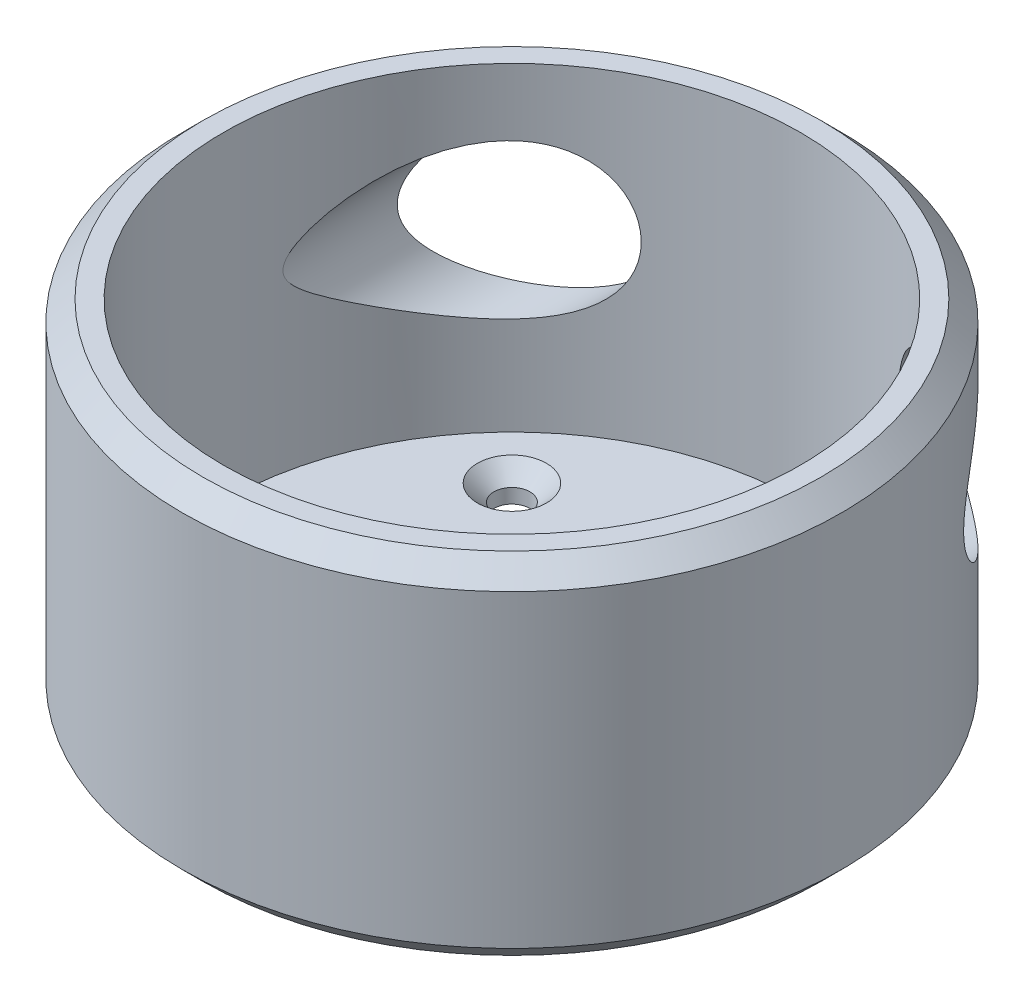
from build123d import *

# Parameters (mm, degrees)
SKETCH2_R           = 32
SKETCH2_R_2         = 28
BOSS_EXTRUDE1_DEPTH = 34
SKETCH3_R           = 28
BOSS_EXTRUDE2_DEPTH = 3
SKETCH4_R           = 12.5
CUT_EXTRUDE1_DEPTH  = 3
SKETCH5_R           = 2.6
SKETCH5_R_2         = 1.75
CUT_EXTRUDE2_DEPTH  = 4
CHAMFER1_SIZE       = 1.6
CHAMFER2_SIZE       = 2
CHAMFER3_SIZE       = 2
SKETCH7_R           = 7.5
CUT_EXTRUDE4_DEPTH  = 33


with BuildPart() as part:
    # Sketch2 → Boss-Extrude1 (new body)
    with BuildSketch(Plane(origin=(0, 0, 0), x_dir=(1, 0, 0), z_dir=(0, 1, 0))):
        Circle(SKETCH2_R)
        Circle(SKETCH2_R_2, mode=Mode.SUBTRACT)
    extrude(amount=BOSS_EXTRUDE1_DEPTH)

    # Sketch3 → Boss-Extrude2 (add)
    with BuildSketch(Plane.XZ):
        Circle(SKETCH3_R)
    extrude(amount=-BOSS_EXTRUDE2_DEPTH)

    # Sketch4 → Cut-Extrude1 (cut)
    with BuildSketch(Plane(origin=(0, 3, 0), x_dir=(1, 0, 0), z_dir=(0, 1, 0))):
        Circle(SKETCH4_R)
    extrude(amount=-CUT_EXTRUDE1_DEPTH, mode=Mode.SUBTRACT)

    # Sketch5 → Cut-Extrude2 (cut, through all)
    with BuildSketch(Plane(origin=(0, 3, 0), x_dir=(1, 0, 0), z_dir=(0, 1, 0))):
        Circle(SKETCH5_R)
        with Locations((-15.5, 15.5)):
            Circle(SKETCH5_R_2)
        with Locations((15.5, 15.5)):
            Circle(SKETCH5_R_2)
        with Locations((-15.5, -15.5)):
            Circle(SKETCH5_R_2)
        with Locations((15.5, -15.5)):
            Circle(SKETCH5_R_2)
    extrude(amount=-CUT_EXTRUDE2_DEPTH, mode=Mode.SUBTRACT)

    # Chamfer1
    chamfer1_edges = [part.edges().sort_by_distance(p)[0] for p in [
        (13.75, 3, 15.5),
        (-17.25, 3, 15.5),
        (13.75, 3, -15.5),
        (-17.25, 3, -15.5),
    ]]
    chamfer(chamfer1_edges, length=CHAMFER1_SIZE)

    # Chamfer2
    chamfer2_edges = [part.edges().sort_by_distance(p)[0] for p in [
        (-32, 0, 0),
    ]]
    chamfer(chamfer2_edges, length=CHAMFER2_SIZE)

    # Chamfer3
    chamfer3_edges = [part.edges().sort_by_distance(p)[0] for p in [
        (-32, 34, 0),
    ]]
    chamfer(chamfer3_edges, length=CHAMFER3_SIZE)

    # Sketch7 → Cut-Extrude4 (cut, through all)
    with BuildSketch(Plane.XY):
        with Locations((-20, 20)):
            Circle(SKETCH7_R)
        with Locations((20, 20)):
            Circle(SKETCH7_R)
    extrude(amount=-CUT_EXTRUDE4_DEPTH, mode=Mode.SUBTRACT)


solid = part.part
